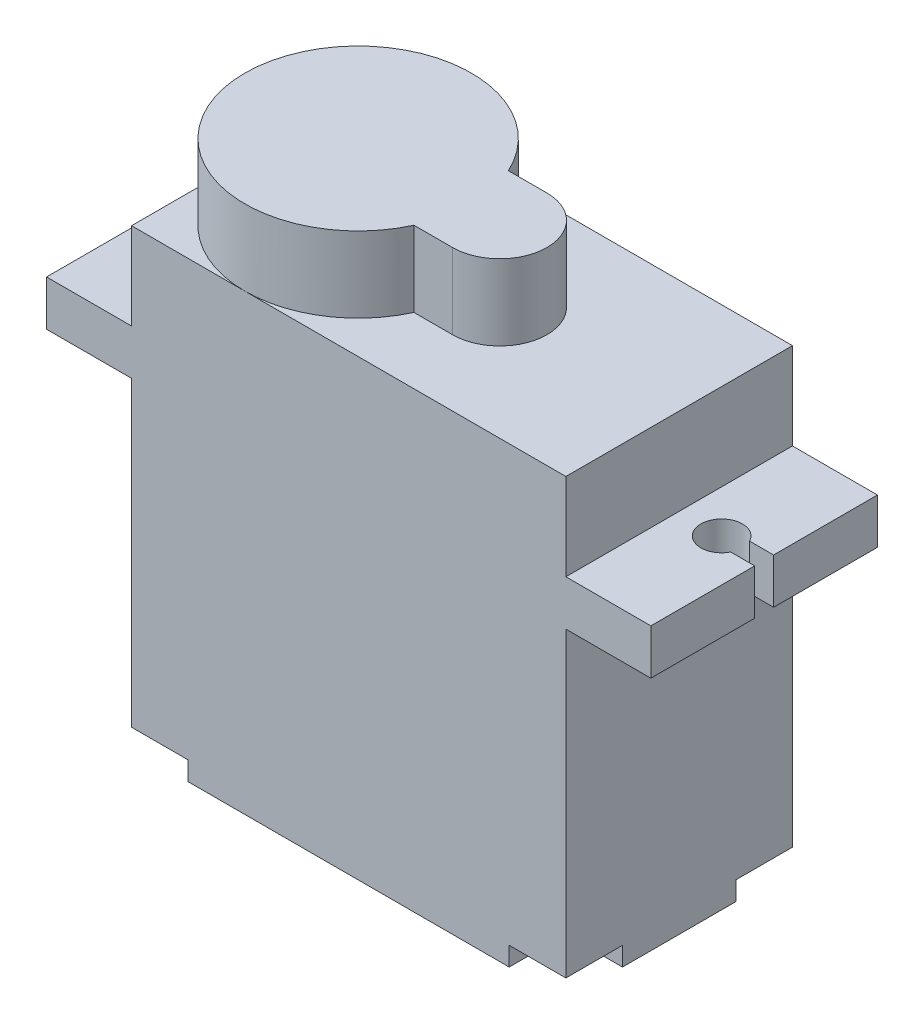
from build123d import *

# Parameters (mm, degrees)
IZIM1_W                     = 23
IZIM1_H                     = 12
Y_KSEKLIK_EKSTR_ZYON1_DEPTH = 24
Y_KSEKLIK_EKSTR_ZYON2_DEPTH = 2.4
Y_KSEKLIK_EKSTR_ZYON3_DEPTH = 4
KES_EKSTR_ZYON1_DEPTH       = 1
IZIM5_W                     = 2.5
IZIM5_H                     = 3.5
KES_EKSTR_ZYON2_DEPTH       = 1
IZIM6_W                     = 2
IZIM6_H                     = 3.5
KES_EKSTR_ZYON3_DEPTH       = 3
PAH1_SIZE                   = 2
PAH1_SIZE2                  = 0.997163216


with BuildPart() as part:
    # Çizim1 → Yükseklik-Ekstrüzyon1 (new body)
    with BuildSketch(Plane(origin=(0, 0, 0), x_dir=(1, 0, 0), z_dir=(0, 1, 0))):
        Rectangle(IZIM1_W, IZIM1_H)
    extrude(amount=Y_KSEKLIK_EKSTR_ZYON1_DEPTH)

    # Çizim2 → Yükseklik-Ekstrüzyon2 (add)
    with BuildSketch(Plane(origin=(0, 17, 0), x_dir=(-1, 0, 0), z_dir=(0, -1, 0))):
        with BuildLine():
            Line((-16, 6), (16, 6))
            Line((16, 6), (16, 0.5))
            Line((16, 0.5), (14.729795897, 0.5))
            ThreePointArc((14.729795897, 0.5), (12.65, 0), (14.729795897, -0.5))
            Line((14.729795897, -0.5), (16, -0.5))
            Line((16, -0.5), (16, -6))
            Line((16, -6), (-16, -6))
            Line((-16, -6), (-16, -0.5))
            Line((-16, -0.5), (-14.729795897, -0.5))
            ThreePointArc((-14.729795897, -0.5), (-12.65, 0), (-14.729795897, 0.5))
            Line((-14.729795897, 0.5), (-16, 0.5))
            Line((-16, 0.5), (-16, 6))
        make_face()
    extrude(amount=-Y_KSEKLIK_EKSTR_ZYON2_DEPTH)

    # Çizim3 → Yükseklik-Ekstrüzyon3 (add)
    with BuildSketch(Plane(origin=(0, 24, 0), x_dir=(1, 0, 0), z_dir=(0, 1, 0))):
        with BuildLine():
            Line((2, -2.5), (-0.045643943, -2.5))
            ThreePointArc((-0.045643943, -2.5), (-11.5, 0), (-0.045643943, 2.5))
            Line((-0.045643943, 2.5), (2, 2.5))
            ThreePointArc((2, 2.5), (4.5, 0), (2, -2.5))
        make_face()
    extrude(amount=Y_KSEKLIK_EKSTR_ZYON3_DEPTH)

    # Çizim4 → Kes-Ekstrüzyon1 (cut)
    with BuildSketch(Plane.XZ):
        with BuildLine():
            Line((-11.5, 6), (-8.5, 6))
            Line((-8.5, 6), (-8.5, 4.5))
            ThreePointArc((-8.5, 4.5), (-8.939339828, 3.439339828), (-10, 3))
            Line((-10, 3), (-11.5, 3))
            Line((-11.5, 3), (-11.5, 6))
        make_face()
        with BuildLine():
            Line((-11.5, -6), (-8.5, -6))
            Line((-8.5, -6), (-8.5, -4.5))
            ThreePointArc((-8.5, -4.5), (-8.939339828, -3.439339828), (-10, -3))
            Line((-10, -3), (-11.5, -3))
            Line((-11.5, -3), (-11.5, -6))
        make_face()
        with BuildLine():
            Line((11.5, 3), (10, 3))
            ThreePointArc((10, 3), (8.939339828, 3.439339828), (8.5, 4.5))
            Line((8.5, 4.5), (8.5, 6))
            Line((8.5, 6), (11.5, 6))
            Line((11.5, 6), (11.5, 3))
        make_face()
        with BuildLine():
            Line((11.5, -3), (10, -3))
            ThreePointArc((10, -3), (8.939339828, -3.439339828), (8.5, -4.5))
            Line((8.5, -4.5), (8.5, -6))
            Line((8.5, -6), (11.5, -6))
            Line((11.5, -6), (11.5, -3))
        make_face()
    extrude(amount=-KES_EKSTR_ZYON1_DEPTH, mode=Mode.SUBTRACT)

    # Çizim5 → Kes-Ekstrüzyon2 (cut)
    with BuildSketch(Plane.XZ):
        with Locations((-10.25, 0)):
            Rectangle(IZIM5_W, IZIM5_H)
    extrude(amount=-KES_EKSTR_ZYON2_DEPTH, mode=Mode.SUBTRACT)

    # Çizim6 → Kes-Ekstrüzyon3 (cut)
    with BuildSketch(Plane.XZ.offset(-1)):
        with Locations((-10, 0)):
            Rectangle(IZIM6_W, IZIM6_H)
    extrude(amount=-KES_EKSTR_ZYON3_DEPTH, mode=Mode.SUBTRACT)

    # Pah1
    pah1_edges = [part.edges().sort_by_distance(p)[0] for p in [
        (-11.5, 0, 2.375),
        (-11.5, 0, -2.375),
    ]]
    pah1_side = [part.faces().sort_by_distance(p)[0] for p in [
        (0.384625419, 0, 0),
    ]]
    chamfer(pah1_edges, length=PAH1_SIZE, length2=PAH1_SIZE2, reference=pah1_side[0])


solid = part.part
